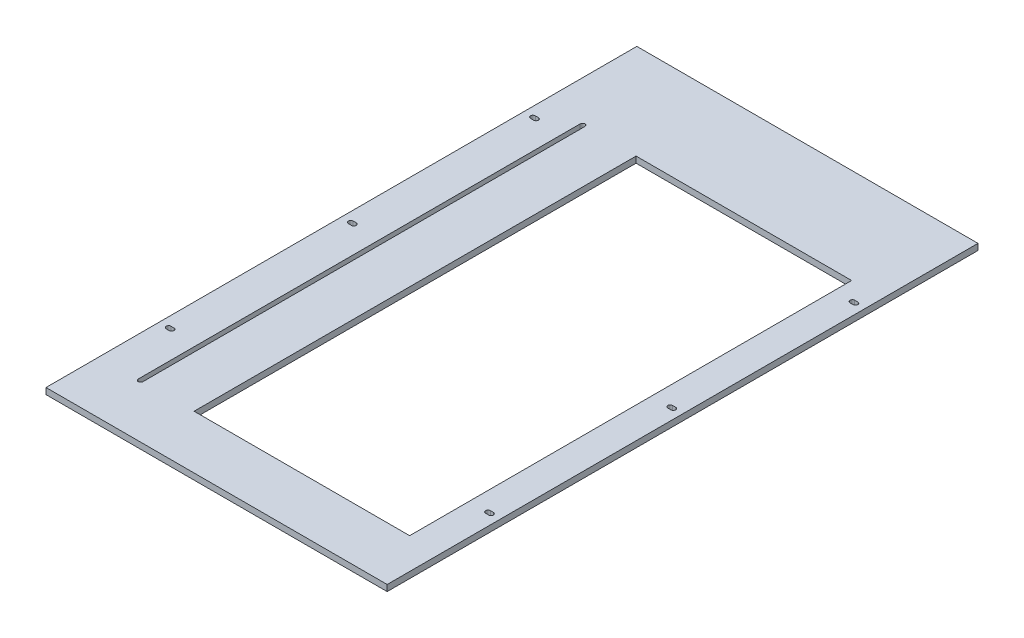
from build123d import *

# Parameters (mm, degrees)
SKETCH_1_W      = 220
SKETCH_1_H      = 381
SKETCH_1_W_2    = 139
SKETCH_1_H_2    = 285
EXTRUDE_1_DEPTH = 4


with BuildPart() as part:
    # 草圖1 → 填料-伸長1 (new body)
    with BuildSketch(Plane.XZ.offset(4)):
        with Locations((-3.755314961, -3.521610711)):
            Rectangle(SKETCH_1_W, SKETCH_1_H)
        with BuildLine():
            Line((-85.755314961, 152.478389289), (-85.755314961, -132.521610711))
            ThreePointArc((-85.755314961, -132.521610711), (-87.255314961, -134.021610711), (-88.755314961, -132.521610711))
            Line((-88.755314961, -132.521610711), (-88.755314961, 152.478389289))
            ThreePointArc((-88.755314961, 152.478389289), (-87.255314961, 153.978389289), (-85.755314961, 152.478389289))
        make_face(mode=Mode.SUBTRACT)
        with BuildLine():
            Line((-105.755314961, -122.521610711), (-107.755314961, -122.521610711))
            ThreePointArc((-107.755314961, -122.521610711), (-109.255314961, -121.021610711), (-107.755314961, -119.521610711))
            Line((-107.755314961, -119.521610711), (-105.755314961, -119.521610711))
            ThreePointArc((-105.755314961, -119.521610711), (-104.255314961, -121.021610711), (-105.755314961, -122.521610711))
        make_face(mode=Mode.SUBTRACT)
        with BuildLine():
            Line((98.244685039, 115.478389289), (100.244685039, 115.478389289))
            ThreePointArc((100.244685039, 115.478389289), (101.744685039, 113.978389289), (100.244685039, 112.478389289))
            Line((100.244685039, 112.478389289), (98.244685039, 112.478389289))
            ThreePointArc((98.244685039, 112.478389289), (96.744685039, 113.978389289), (98.244685039, 115.478389289))
        make_face(mode=Mode.SUBTRACT)
        with BuildLine():
            Line((98.244685039, -2.021610711), (100.244685039, -2.021610711))
            ThreePointArc((100.244685039, -2.021610711), (101.744685039, -3.521610711), (100.244685039, -5.021610711))
            Line((100.244685039, -5.021610711), (98.244685039, -5.021610711))
            ThreePointArc((98.244685039, -5.021610711), (96.744685039, -3.521610711), (98.244685039, -2.021610711))
        make_face(mode=Mode.SUBTRACT)
        with BuildLine():
            Line((-107.755314961, -2.021610711), (-105.755314961, -2.021610711))
            ThreePointArc((-105.755314961, -2.021610711), (-104.255314961, -3.521610711), (-105.755314961, -5.021610711))
            Line((-105.755314961, -5.021610711), (-107.755314961, -5.021610711))
            ThreePointArc((-107.755314961, -5.021610711), (-109.255314961, -3.521610711), (-107.755314961, -2.021610711))
        make_face(mode=Mode.SUBTRACT)
        with BuildLine():
            Line((-107.755314961, 115.478389289), (-105.755314961, 115.478389289))
            ThreePointArc((-105.755314961, 115.478389289), (-104.255314961, 113.978389289), (-105.755314961, 112.478389289))
            Line((-105.755314961, 112.478389289), (-107.755314961, 112.478389289))
            ThreePointArc((-107.755314961, 112.478389289), (-109.255314961, 113.978389289), (-107.755314961, 115.478389289))
        make_face(mode=Mode.SUBTRACT)
        with BuildLine():
            Line((98.244685039, -119.521610711), (100.244685039, -119.521610711))
            ThreePointArc((100.244685039, -119.521610711), (101.744685039, -121.021610711), (100.244685039, -122.521610711))
            Line((100.244685039, -122.521610711), (98.244685039, -122.521610711))
            ThreePointArc((98.244685039, -122.521610711), (96.744685039, -121.021610711), (98.244685039, -119.521610711))
        make_face(mode=Mode.SUBTRACT)
        with Locations((16.744685039, 9.978389289)):
            Rectangle(SKETCH_1_W_2, SKETCH_1_H_2, mode=Mode.SUBTRACT)
    extrude(amount=-EXTRUDE_1_DEPTH)


solid = part.part
